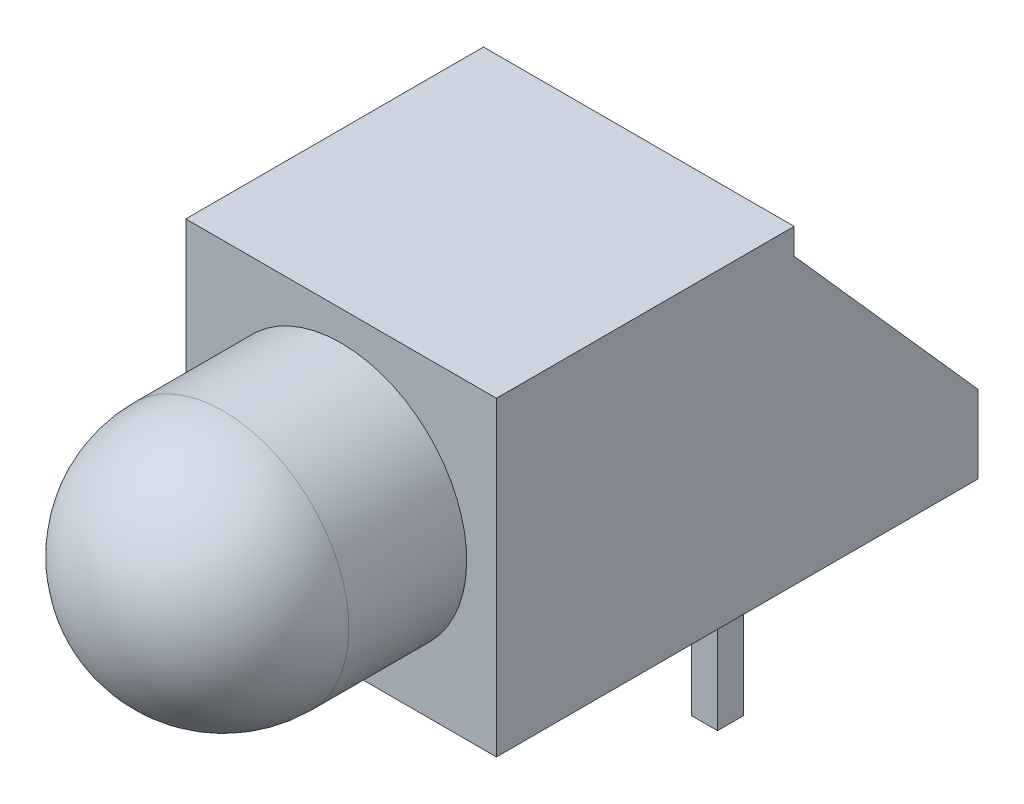
from build123d import *

# Parameters (mm, degrees)
BOSS_EXTRUDE1_DEPTH = 3
SKETCH3_W           = 0.5
SKETCH3_H           = 0.5
BOSS_EXTRUDE2_DEPTH = 3.175


with BuildPart() as part:
    # Sketch1 → Boss-Extrude1 (new body, symmetric)
    with BuildSketch(Plane(origin=(0, 0, 0), x_dir=(0, 0, -1), z_dir=(1, 0, 0))):
        Polygon((-6, 6), (-6, 0), (3.3, 0), (3.3, 1.5), (-0.25, 5.5), (-0.25, 6), align=None)
    extrude(amount=BOSS_EXTRUDE1_DEPTH, both=True)

    # Sketch2 → Revolve1 (revolve)
    with BuildSketch(Plane(origin=(0, 0, 0), x_dir=(0, 0, -1), z_dir=(1, 0, 0))):
        with BuildLine():
            Line((-6, 3), (-10.7, 3))
            ThreePointArc((-10.7, 3), (-9.989733944, 4.714733944), (-8.275, 5.425))
            Line((-8.275, 5.425), (-6, 5.425))
            Line((-6, 5.425), (-6, 3))
        make_face()
    revolve(axis=Axis((0, 3, 6), (0, 0, 1)))

    # Sketch3 → Boss-Extrude2 (add)
    with BuildSketch(Plane.XZ):
        with Locations((-1.27, 0)):
            Rectangle(SKETCH3_W, SKETCH3_H)
        with Locations((1.27, 0)):
            Rectangle(SKETCH3_W, SKETCH3_H)
    extrude(amount=BOSS_EXTRUDE2_DEPTH)


solid = part.part
